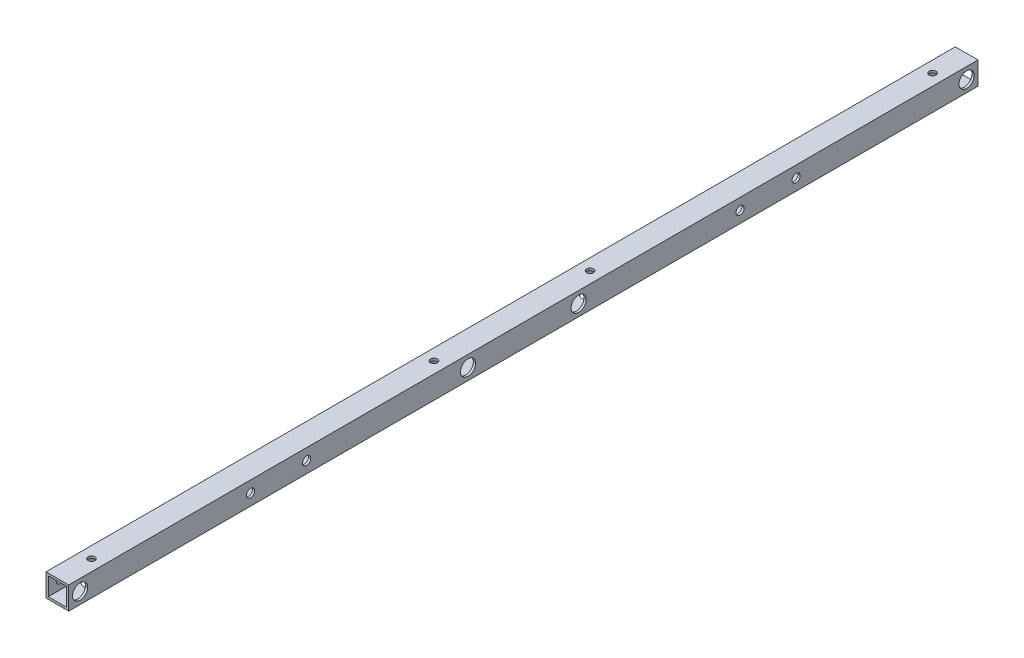
from build123d import *

# Parameters (mm, degrees)
SKETCH_1_W           = 15
SKETCH_1_H           = 15
SKETCH_1_W_2         = 12
SKETCH_1_H_2         = 12
EXTRUDE_1_DEPTH      = 600
SKETCH_2_R           = 2.25
CUT_EXTRUDE_1_DEPTH  = 25
SKETCH_3_R           = 2.25
CUT_EXTRUDE_2_DEPTH  = 25
SKETCH_4_R           = 2.25
CUT_EXTRUDE_3_DEPTH  = 20
SKETCH_5_R           = 5
CUT_EXTRUDE_4_DEPTH  = 10
SKETCH_6_R           = 5
CUT_EXTRUDE_5_DEPTH  = 10
SKETCH_7_R           = 2.7
CUT_EXTRUDE_10_DEPTH = 30
SKETCH_8_R           = 5
CUT_EXTRUDE_11_DEPTH = 5


with BuildPart() as part:
    # ｽｹｯﾁ1 → ﾎﾞｽ - 押し出し1 (new body)
    with BuildSketch(Plane.XY):
        Rectangle(SKETCH_1_W, SKETCH_1_H)
        Rectangle(SKETCH_1_W_2, SKETCH_1_H_2, mode=Mode.SUBTRACT)
    extrude(amount=EXTRUDE_1_DEPTH)

    # ｽｹｯﾁ2 → ｶｯﾄ - 押し出し1 (cut)
    with BuildSketch(Plane(origin=(7.5, 0, 0), x_dir=(0, 0, -1), z_dir=(1, 0, 0))):
        with Locations((-592.5, 0)):
            Circle(SKETCH_2_R)
        with Locations((-7.5, 0)):
            Circle(SKETCH_2_R)
    extrude(amount=-CUT_EXTRUDE_1_DEPTH, mode=Mode.SUBTRACT)

    # ｽｹｯﾁ3 → ｶｯﾄ - 押し出し2 (cut)
    with BuildSketch(Plane(origin=(0, 7.5, 0), x_dir=(1, 0, 0), z_dir=(0, 1, 0))):
        with Locations((0, -22.5)):
            Circle(SKETCH_3_R)
        with Locations((0, -577.5)):
            Circle(SKETCH_3_R)
        with Locations((0, -248.5)):
            Circle(SKETCH_3_R)
        with Locations((0, -351.5)):
            Circle(SKETCH_3_R)
    extrude(amount=-CUT_EXTRUDE_2_DEPTH, mode=Mode.SUBTRACT)

    # ｽｹｯﾁ4 → ｶｯﾄ - 押し出し3 (cut)
    with BuildSketch(Plane(origin=(7.5, 0, 0), x_dir=(0, 0, -1), z_dir=(1, 0, 0))):
        with Locations((-336.5, 0)):
            Circle(SKETCH_4_R)
        with Locations((-263.5, 0)):
            Circle(SKETCH_4_R)
    extrude(amount=-CUT_EXTRUDE_3_DEPTH, mode=Mode.SUBTRACT)

    # ｽｹｯﾁ5 → ｶｯﾄ - 押し出し4 (cut)
    with BuildSketch(Plane(origin=(7.5, 0, 0), x_dir=(0, 0, -1), z_dir=(1, 0, 0))):
        with Locations((-592.5, 0)):
            Circle(SKETCH_5_R)
        with Locations((-336.5, 0)):
            Circle(SKETCH_5_R)
        with Locations((-263.5, 0)):
            Circle(SKETCH_5_R)
        with Locations((-7.5, 0)):
            Circle(SKETCH_5_R)
    extrude(amount=-CUT_EXTRUDE_4_DEPTH, mode=Mode.SUBTRACT)

    # ｽｹｯﾁ6 → ｶｯﾄ - 押し出し5 (cut)
    with BuildSketch(Plane(origin=(0, -7.5, 0), x_dir=(-1, 0, 0), z_dir=(0, -1, 0))):
        with Locations((0, -577.5)):
            Circle(SKETCH_6_R)
        with Locations((0, -22.5)):
            Circle(SKETCH_6_R)
        with Locations((0, -248.5)):
            Circle(SKETCH_6_R)
        with Locations((0, -351.5)):
            Circle(SKETCH_6_R)
    extrude(amount=-CUT_EXTRUDE_5_DEPTH, mode=Mode.SUBTRACT)

    # ｽｹｯﾁ7 → ｶｯﾄ - 押し出し10 (cut)
    with BuildSketch(Plane(origin=(7.5, 0, 0), x_dir=(0, 1, 0), z_dir=(-1, 0, 0))):
        with Locations((0, -120)):
            Circle(SKETCH_7_R)
        with Locations((0, -157)):
            Circle(SKETCH_7_R)
        with Locations((0, -443)):
            Circle(SKETCH_7_R)
        with Locations((0, -480)):
            Circle(SKETCH_7_R)
    extrude(amount=CUT_EXTRUDE_10_DEPTH, mode=Mode.SUBTRACT)

    # ｽｹｯﾁ8 → ｶｯﾄ - 押し出し11 (cut)
    with BuildSketch(Plane.ZY.offset(7.5)):
        with Locations((120, 0)):
            Circle(SKETCH_8_R)
        with Locations((157, 0)):
            Circle(SKETCH_8_R)
        with Locations((443, 0)):
            Circle(SKETCH_8_R)
        with Locations((480, 0)):
            Circle(SKETCH_8_R)
    extrude(amount=-CUT_EXTRUDE_11_DEPTH, mode=Mode.SUBTRACT)


solid = part.part
